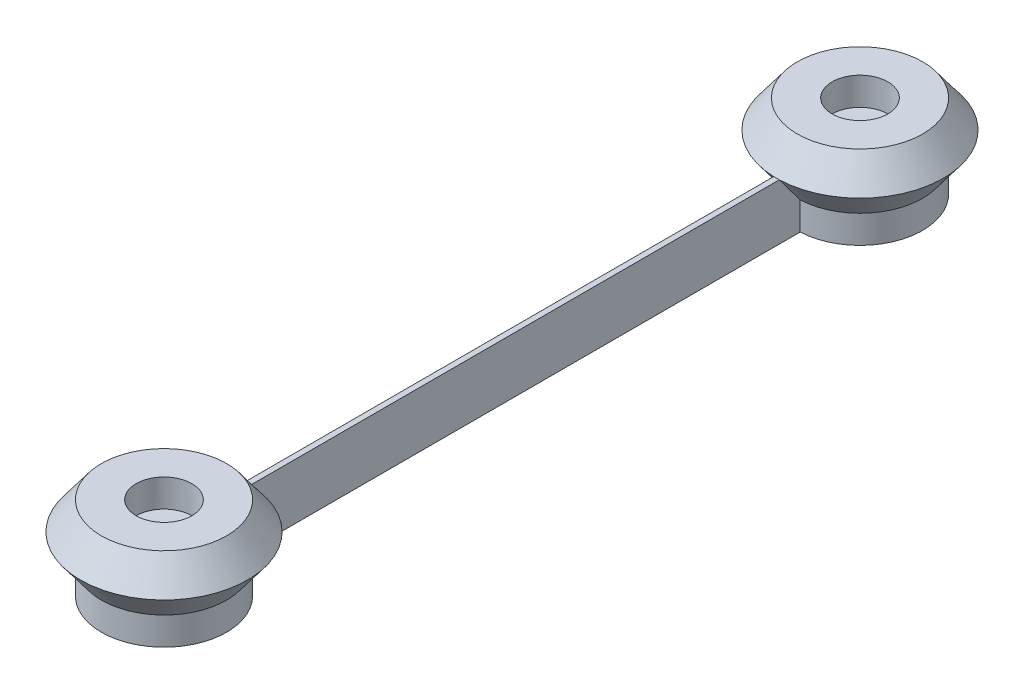
from build123d import *

# Parameters (mm, degrees)
SKETCH2_W           = 0.8
SKETCH2_H           = 92
BOSS_EXTRUDE1_DEPTH = 8


with BuildPart() as part:
    # Sketch1 → Revolve1 (revolve)
    with BuildSketch(Plane(origin=(0, 0, 0), x_dir=(0, 0, -1), z_dir=(1, 0, 0))):
        Polygon((1.5, 0), (1.5, 8), (4, 8), (4, 12), (9, 12), (12, 8), (9, 4), (9, 0), align=None)
    revolve(axis=Axis((0, 55, 0), (0, -1, 0)))


with BuildPart() as body_2:
    # Mirror2: mirrored copy
    add(part.part.mirror(Plane.XY.offset(-50)))


with BuildPart() as part_1:
    add(part.part)

    add(body_2.part)  # Boss-Extrude1 merges body 2
    # Sketch2 → Boss-Extrude1 (add)
    with BuildSketch(Plane(origin=(0, 0, 0), x_dir=(1, 0, 0), z_dir=(0, 1, 0))):
        with Locations((0, 50)):
            Rectangle(SKETCH2_W, SKETCH2_H)
    extrude(amount=BOSS_EXTRUDE1_DEPTH)


solid = part_1.part
